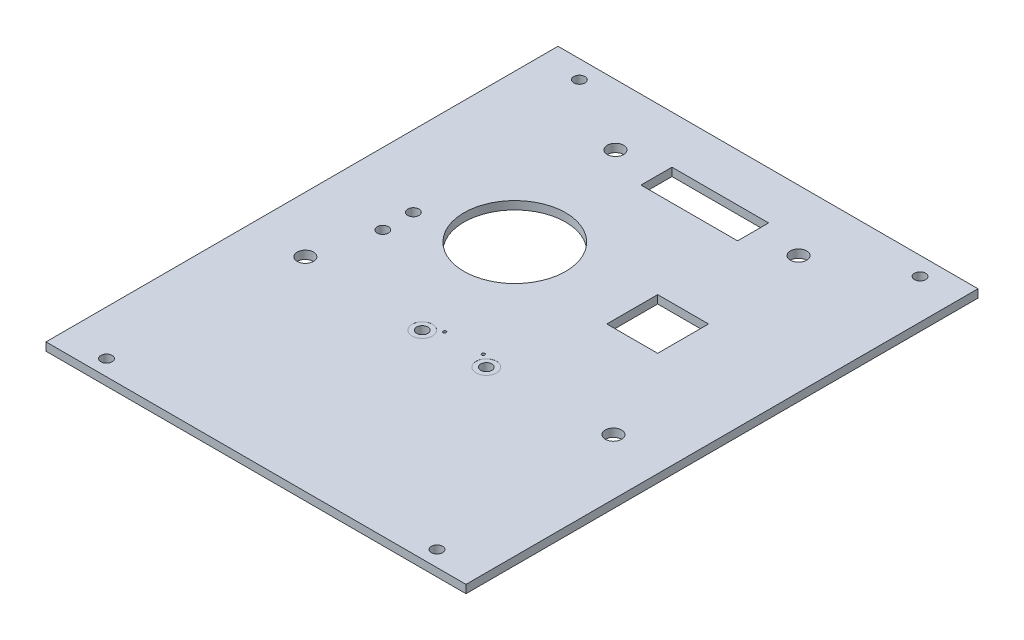
from build123d import *

# Parameters (mm, degrees)
BOSS_EXTRUDE1_DEPTH            = 1.6
F_2_2_2_2_DIAMETER_HOLE1_D     = 2.2
F_2_2_2_2_DIAMETER_HOLE1_DEPTH = 5
SKETCH9_R                      = 10
CUT_EXTRUDE4_DEPTH             = 2.6
SKETCH15_W                     = 83
SKETCH15_H                     = 2.5
CUT_EXTRUDE8_DEPTH             = 2.6
SKETCH37_W                     = 83
SKETCH37_H                     = 1.6
EXTRUDE1_DEPTH                 = 1.6
SKETCH38_W                     = 83
SKETCH38_H                     = 1.6
EXTRUDE2_DEPTH                 = 1.6
F_2_2_2_2_DIAMETER_HOLE4_D     = 2.2
F_2_2_2_2_DIAMETER_HOLE4_DEPTH = 1.6
SKETCH49_W                     = 0.2
SKETCH49_H                     = 100.7
EXTRUDE5_DEPTH                 = 2.6
SKETCH51_W                     = 10
SKETCH51_H                     = 10
CUT_EXTRUDE9_DEPTH             = 10
SKETCH52_W                     = 19
SKETCH52_H                     = 6.1
CUT_EXTRUDE10_DEPTH            = 2.6
SKETCH_2_R                     = 1.6
CUT_EXTRUDE_2_DEPTH            = 10
SKETCH_8_R                     = 0.3
CUT_EXTRUDE_3_DEPTH            = 10
SKETCH_9_R                     = 1.1
CUT_EXTRUDE_4_DEPTH            = 10
SKETCH_10_R                    = 2
CUT_EXTRUDE_5_DEPTH            = 0.01
SKETCH_11_R                    = 1.1
CUT_EXTRUDE_6_DEPTH            = 10


with BuildPart() as part:
    # Sketch1 → Boss-Extrude1 (new body)
    with BuildSketch(Plane(origin=(0, 0, 0), x_dir=(1, 0, 0), z_dir=(0, 1, 0))):
        Polygon((65.24, 0.272495156), (65.24, -46.437452638), (65.24, -63.637452638), (65.24, -70.137452638), (-17.76, -70.137452638), (-17.76, -63.637452638), (-17.76, -48.637452638), (-17.76, -45.78978272), (-17.76, 4.362547362), (-17.76, 21.562547362), (-17.76, 29.862547362), (65.24, 29.862547362), (65.24, 21.562547362), (65.24, 6.562547362), align=None)
    extrude(amount=BOSS_EXTRUDE1_DEPTH)

    # Ø2.2 (2.2) Diameter Hole1
    with Locations(Plane(origin=(0, 1.6, 0), x_dir=(1, 0, 0), z_dir=(0, 1, 0))):
        with Locations((57.24, 27.862547362), (-9.76, 27.862547362)):
            Hole(F_2_2_2_2_DIAMETER_HOLE1_D / 2, depth=F_2_2_2_2_DIAMETER_HOLE1_DEPTH)

    # Sketch9 → Cut-Extrude4 (cut, through all)
    with BuildSketch(Plane(origin=(0, 0, 0), x_dir=(-1, 0, 0), z_dir=(0, -1, 0))):
        with Locations((-11.54, -6.137452638)):
            Circle(SKETCH9_R)
    extrude(amount=-CUT_EXTRUDE4_DEPTH, mode=Mode.SUBTRACT)

    # Sketch15 → Cut-Extrude8 (cut, through all)
    with BuildSketch(Plane.XZ):
        with Locations((23.74, 68.887452638)):
            Rectangle(SKETCH15_W, SKETCH15_H)
    extrude(amount=-CUT_EXTRUDE8_DEPTH, mode=Mode.SUBTRACT)

    # Sketch37 → Extrude1 (add)
    with BuildSketch(Plane(origin=(0, 0, -29.862547362), x_dir=(-1, 0, 0), z_dir=(0, 0, -1))):
        with Locations((-23.74, 0.8)):
            Rectangle(SKETCH37_W, SKETCH37_H)
    extrude(amount=EXTRUDE1_DEPTH)

    # Sketch38 → Extrude2 (add)
    with BuildSketch(Plane.XY.offset(67.637452638)):
        with Locations((23.74, 0.8)):
            Rectangle(SKETCH38_W, SKETCH38_H)
    extrude(amount=EXTRUDE2_DEPTH)

    # Ø2.2 (2.2) Diameter Hole4
    with Locations(Plane(origin=(0, 1.6, 0), x_dir=(1, 0, 0), z_dir=(0, 1, 0))):
        with Locations((-8.76, -66.137452638), (56.24, -66.137452638)):
            Hole(F_2_2_2_2_DIAMETER_HOLE4_D / 2, depth=F_2_2_2_2_DIAMETER_HOLE4_DEPTH)

    # Sketch49 → Extrude5 (cut, through all)
    with BuildSketch(Plane.XZ):
        with Locations((65.14, 18.887452638)):
            Rectangle(SKETCH49_W, SKETCH49_H)
        with Locations((-17.66, 18.887452638)):
            Rectangle(SKETCH49_W, SKETCH49_H)
    extrude(amount=-EXTRUDE5_DEPTH, mode=Mode.SUBTRACT)

    # Sketch51 → Cut-Extrude9 (cut)
    with BuildSketch(Plane.XZ):
        with Locations((39.54, 6.037452638)):
            Rectangle(SKETCH51_W, SKETCH51_H)
    extrude(amount=-CUT_EXTRUDE9_DEPTH, mode=Mode.SUBTRACT)

    # Sketch52 → Cut-Extrude10 (cut, through all)
    with BuildSketch(Plane.XZ):
        with Locations((23.74, -19.027547362)):
            Rectangle(SKETCH52_W, SKETCH52_H)
    extrude(amount=-CUT_EXTRUDE10_DEPTH, mode=Mode.SUBTRACT)

    # ｽｹｯﾁ2 → ｶｯﾄ - 押し出し2 (cut)
    with BuildSketch(Plane(origin=(0, 0, 0), x_dir=(-1, 0, 0), z_dir=(0, -1, 0))):
        with Locations((-54.04, -29.237452638)):
            Circle(SKETCH_2_R)
        with Locations((6.56, -29.237452638)):
            Circle(SKETCH_2_R)
        with Locations((-41.74, 19.462547362)):
            Circle(SKETCH_2_R)
        with Locations((-5.74, 19.462547362)):
            Circle(SKETCH_2_R)
    extrude(amount=-CUT_EXTRUDE_2_DEPTH, mode=Mode.SUBTRACT)

    # ｽｹｯﾁ8 → ｶｯﾄ - 押し出し3 (cut)
    with BuildSketch(Plane(origin=(0, 1.6, 0), x_dir=(1, 0, 0), z_dir=(0, 1, 0))):
        with Locations((27.54, -28.337452638)):
            Circle(SKETCH_8_R)
        with Locations((19.94, -28.337452638)):
            Circle(SKETCH_8_R)
    extrude(amount=-CUT_EXTRUDE_3_DEPTH, mode=Mode.SUBTRACT)

    # ｽｹｯﾁ9 → ｶｯﾄ - 押し出し4 (cut)
    with BuildSketch(Plane(origin=(0, 1.6, 0), x_dir=(1, 0, 0), z_dir=(0, 1, 0))):
        with Locations((30.04, -30.237452638)):
            Circle(SKETCH_9_R)
        with Locations((17.44, -30.237452638)):
            Circle(SKETCH_9_R)
    extrude(amount=-CUT_EXTRUDE_4_DEPTH, mode=Mode.SUBTRACT)

    # ｽｹｯﾁ10 → ｶｯﾄ - 押し出し5 (cut)
    with BuildSketch(Plane(origin=(0, 1.6, 0), x_dir=(1, 0, 0), z_dir=(0, 1, 0))):
        with Locations((30.04, -30.237452638)):
            Circle(SKETCH_10_R)
        with Locations((17.44, -30.237452638)):
            Circle(SKETCH_10_R)
    extrude(amount=-CUT_EXTRUDE_5_DEPTH, mode=Mode.SUBTRACT)

    # ｽｹｯﾁ11 → ｶｯﾄ - 押し出し6 (cut)
    with BuildSketch(Plane(origin=(0, 1.6, 0), x_dir=(1, 0, 0), z_dir=(0, 1, 0))):
        with Locations((-3.51, -11.037452638)):
            Circle(SKETCH_11_R)
        with Locations((-3.51, -17.037452638)):
            Circle(SKETCH_11_R)
    extrude(amount=-CUT_EXTRUDE_6_DEPTH, mode=Mode.SUBTRACT)


solid = part.part
